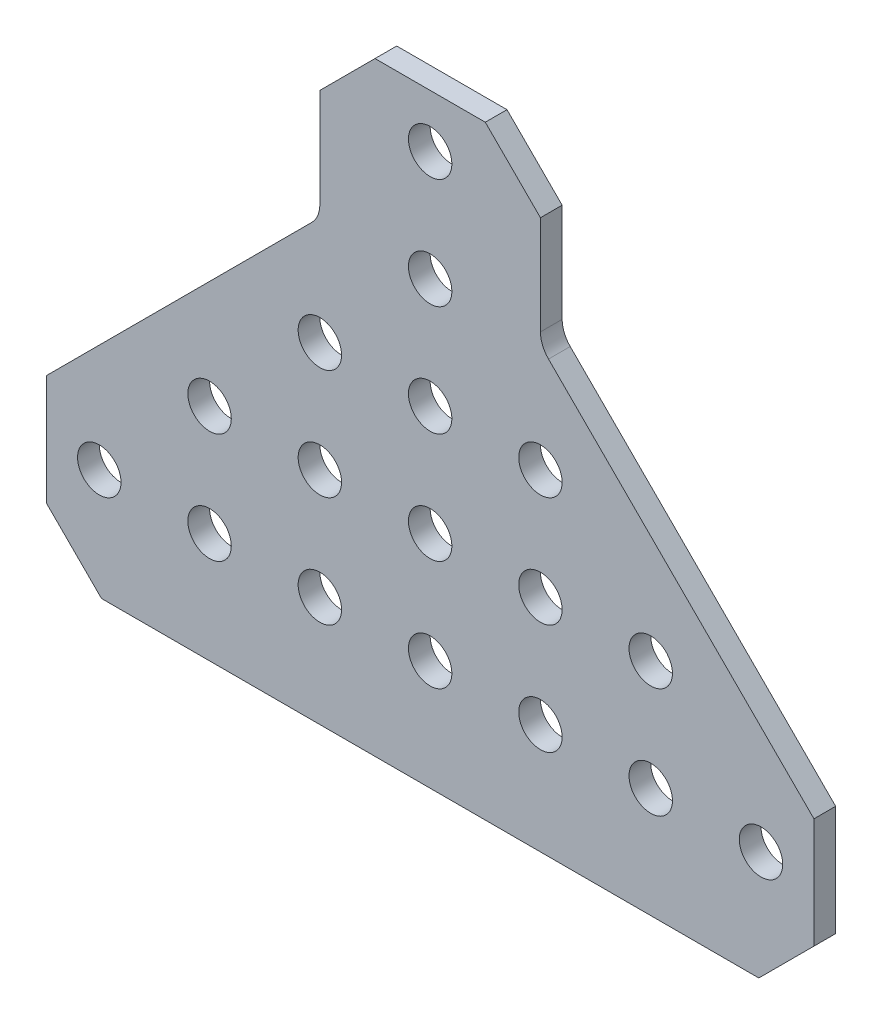
from build123d import *

# Parameters (mm, degrees)
SKETCH1_R           = 2.5
BOSS_EXTRUDE1_DEPTH = 2.5


with BuildPart() as part:
    # Sketch1 → Boss-Extrude1 (new body)
    with BuildSketch(Plane(origin=(0, 0, -1.25), x_dir=(-1, 0, 0), z_dir=(0, 0, -1))):
        with BuildLine():
            Line((44.196, 6.35), (13.62993597, 36.91606403))
            ThreePointArc((13.62993597, 36.91606403), (12.941682484, 37.946108163), (12.7, 39.161128061))
            Line((12.7, 39.161128061), (12.7, 50.546))
            Line((12.7, 50.546), (6.35, 56.896))
            Line((6.35, 56.896), (-6.35, 56.896))
            Line((-6.35, 56.896), (-12.7, 50.546))
            Line((-12.7, 50.546), (-12.7, 39.161128061))
            ThreePointArc((-12.7, 39.161128061), (-12.941682484, 37.946108163), (-13.62993597, 36.91606403))
            Line((-13.62993597, 36.91606403), (-44.196, 6.35))
            Line((-44.196, 6.35), (-44.196, -6.35))
            Line((-44.196, -6.35), (-37.846, -12.7))
            Line((-37.846, -12.7), (37.846, -12.7))
            Line((37.846, -12.7), (44.196, -6.35))
            Line((44.196, -6.35), (44.196, 6.35))
        make_face()
        with Locations((0, 50.8)):
            Circle(SKETCH1_R, mode=Mode.SUBTRACT)
        with Locations((0, 38.1)):
            Circle(SKETCH1_R, mode=Mode.SUBTRACT)
        with Locations((-38.1, 0)):
            Circle(SKETCH1_R, mode=Mode.SUBTRACT)
        with Locations((-25.4, 0)):
            Circle(SKETCH1_R, mode=Mode.SUBTRACT)
        with Locations((-12.7, 0)):
            Circle(SKETCH1_R, mode=Mode.SUBTRACT)
        Circle(SKETCH1_R, mode=Mode.SUBTRACT)
        with Locations((12.7, 0)):
            Circle(SKETCH1_R, mode=Mode.SUBTRACT)
        with Locations((38.1, 0)):
            Circle(SKETCH1_R, mode=Mode.SUBTRACT)
        with Locations((25.4, 0)):
            Circle(SKETCH1_R, mode=Mode.SUBTRACT)
        with Locations((0, 12.7)):
            Circle(SKETCH1_R, mode=Mode.SUBTRACT)
        with Locations((0, 25.4)):
            Circle(SKETCH1_R, mode=Mode.SUBTRACT)
        with Locations((25.4, 12.7)):
            Circle(SKETCH1_R, mode=Mode.SUBTRACT)
        with Locations((12.7, 12.7)):
            Circle(SKETCH1_R, mode=Mode.SUBTRACT)
        with Locations((12.7, 25.4)):
            Circle(SKETCH1_R, mode=Mode.SUBTRACT)
        with Locations((-12.7, 12.7)):
            Circle(SKETCH1_R, mode=Mode.SUBTRACT)
        with Locations((-12.7, 25.4)):
            Circle(SKETCH1_R, mode=Mode.SUBTRACT)
        with Locations((-25.4, 12.7)):
            Circle(SKETCH1_R, mode=Mode.SUBTRACT)
    extrude(amount=-BOSS_EXTRUDE1_DEPTH)


solid = part.part
